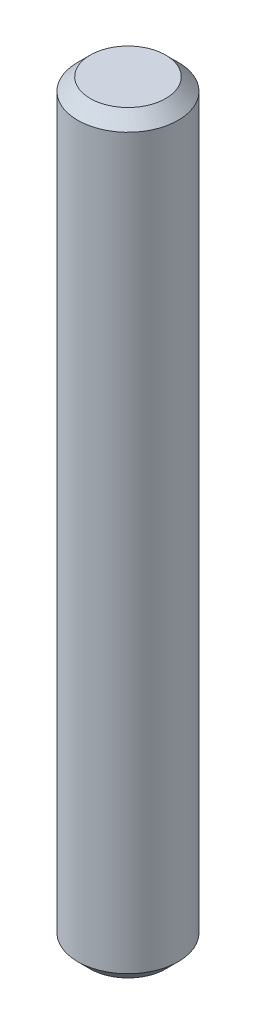
from build123d import *

# Parameters (mm, degrees)
SKETCH1_R           = 2
BOSS_EXTRUDE1_DEPTH = 15
CHAMFER1_SIZE       = 0.5


with BuildPart() as part:
    # Sketch1 → Boss-Extrude1 (new body, symmetric)
    with BuildSketch(Plane(origin=(0, 0, 0), x_dir=(1, 0, 0), z_dir=(0, 1, 0))):
        Circle(SKETCH1_R)
    extrude(amount=BOSS_EXTRUDE1_DEPTH, both=True)

    # Chamfer1
    chamfer1_edges = [part.edges().sort_by_distance(p)[0] for p in [
        (-2, -15, 0),
        (-2, 15, 0),
    ]]
    chamfer(chamfer1_edges, length=CHAMFER1_SIZE)


solid = part.part
